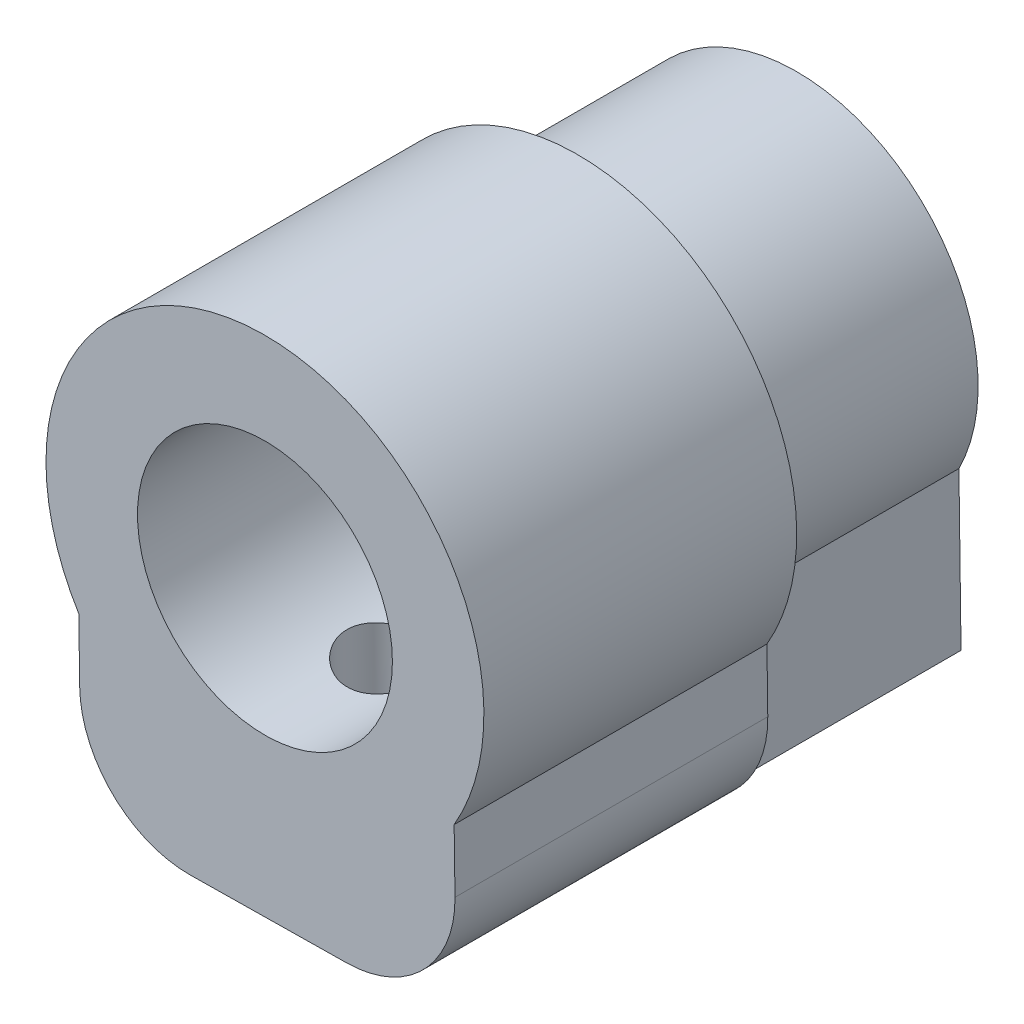
from build123d import *

# Parameters (mm, degrees)
BOSS_EXTRUDE1_DEPTH = 7
BOSS_EXTRUDE3_DEPTH = 10
SKETCH6_R           = 1.35
CUT_EXTRUDE3_DEPTH  = 12
FILLET1_R           = 3.5
FILLET2_R           = 3.5


with BuildPart() as part:
    # Sketch1 → Boss-Extrude1 (new body)
    with BuildSketch(Plane.XY):
        with BuildLine():
            ThreePointArc((5.050452833, -4.633288902), (-0.057176836, -7.835700867), (-5.249547167, -4.77259565))
            Line((-5.249547167, -4.77259565), (-5.181922533, -9.77259565))
            Line((-5.181922533, -9.77259565), (5.118077467, -9.633288902))
            Line((5.118077467, -9.633288902), (5.050452833, -4.633288902))
        make_face()
        with BuildLine():
            ThreePointArc((5.664385761, -2.036231273), (-1.546144107, 3.589638037), (-5.249547167, -4.77259565))
            Line((-5.249547167, -4.77259565), (5.050452833, -4.633288902))
            ThreePointArc((5.050452833, -4.633288902), (5.508816158, -3.370549635), (5.664385761, -2.036231273))
        make_face()
        with BuildLine():
            Line((5.050452833, -4.633288902), (-5.249547167, -4.77259565))
            ThreePointArc((-5.249547167, -4.77259565), (-0.057176836, -7.835700867), (5.050452833, -4.633288902))
        make_face()
    extrude(amount=BOSS_EXTRUDE1_DEPTH)

    # Sketch2 → Boss-Extrude3 (add)
    with BuildSketch(Plane.XY.offset(7)):
        with BuildLine():
            Line((5.063146119, -5.571799449), (5.912597424, -5.560310683))
            ThreePointArc((5.912597424, -5.560310683), (6.622250869, -3.861405013), (6.864385761, -2.036231273))
            ThreePointArc((6.864385761, -2.036231273), (-2.052012342, 4.696332749), (-6.086305185, -5.722594964))
            Line((-6.086305185, -5.722594964), (-5.236853881, -5.711106197))
            Line((-5.236853881, -5.711106197), (-5.249547167, -4.77259565))
            ThreePointArc((-5.249547167, -4.77259565), (-0.214051642, 3.763238321), (5.050452833, -4.633288902))
            Line((5.050452833, -4.633288902), (5.063146119, -5.571799449))
        make_face()
        with BuildLine():
            Line((1.811820806, -5.615773387), (5.063146119, -5.571799449))
            Line((5.063146119, -5.571799449), (5.050452833, -4.633288902))
            ThreePointArc((5.050452833, -4.633288902), (-0.214051642, 3.763238321), (-5.249547167, -4.77259565))
            Line((-5.249547167, -4.77259565), (-5.236853881, -5.711106197))
            Line((-5.236853881, -5.711106197), (-1.985528568, -5.66713226))
            ThreePointArc((-1.985528568, -5.66713226), (-2.264842281, 1.438248968), (3.939385761, -2.036231273))
            ThreePointArc((3.939385761, -2.036231273), (3.367343284, -4.118276805), (1.811820806, -5.615773387))
        make_face()
        with BuildLine():
            Line((5.078495254, -6.706676883), (5.063146119, -5.571799449))
            Line((5.063146119, -5.571799449), (1.811820806, -5.615773387))
            ThreePointArc((1.811820806, -5.615773387), (-0.080505202, -6.110858617), (-1.985528568, -5.66713226))
            Line((-1.985528568, -5.66713226), (-5.236853881, -5.711106197))
            Line((-5.236853881, -5.711106197), (-5.221504746, -6.845983631))
            ThreePointArc((-5.221504746, -6.845983631), (-0.040948408, -9.035591128), (5.078495254, -6.706676883))
        make_face()
        with BuildLine():
            Line((5.118077467, -9.633288902), (5.078495254, -6.706676883))
            ThreePointArc((5.078495254, -6.706676883), (-0.040948408, -9.035591128), (-5.221504746, -6.845983631))
            Line((-5.221504746, -6.845983631), (-5.181922533, -9.77259565))
            Line((-5.181922533, -9.77259565), (5.118077467, -9.633288902))
        make_face()
        with BuildLine():
            Line((5.986984522, -11.060310683), (5.912597424, -5.560310683))
            ThreePointArc((5.912597424, -5.560310683), (5.524642674, -6.154664432), (5.078495254, -6.706676883))
            Line((5.078495254, -6.706676883), (5.118077467, -9.633288902))
            Line((5.118077467, -9.633288902), (-5.181922533, -9.77259565))
            Line((-5.181922533, -9.77259565), (-5.221504746, -6.845983631))
            ThreePointArc((-5.221504746, -6.845983631), (-5.6824181, -6.30623911), (-6.086305185, -5.722594964))
            Line((-6.086305185, -5.722594964), (-6.011918087, -11.222594964))
            Line((-6.011918087, -11.222594964), (5.986984522, -11.060310683))
        make_face()
        with BuildLine():
            ThreePointArc((5.078495254, -6.706676883), (5.524642674, -6.154664432), (5.912597424, -5.560310683))
            Line((5.912597424, -5.560310683), (5.063146119, -5.571799449))
            Line((5.063146119, -5.571799449), (5.078495254, -6.706676883))
        make_face()
        with BuildLine():
            Line((-5.236853881, -5.711106197), (-6.086305185, -5.722594964))
            ThreePointArc((-6.086305185, -5.722594964), (-5.6824181, -6.30623911), (-5.221504746, -6.845983631))
            Line((-5.221504746, -6.845983631), (-5.236853881, -5.711106197))
        make_face()
    extrude(amount=BOSS_EXTRUDE3_DEPTH)

    # Sketch6 → Cut-Extrude3 (cut)
    with BuildSketch(Plane(origin=(0.150657496, -11.139246579, 0), x_dir=(-0.999908551, -0.01352369, 0), z_dir=(0.01352369, -0.999908551, 0))):
        with Locations((0.241163233, -13)):
            Circle(SKETCH6_R)
    extrude(amount=-CUT_EXTRUDE3_DEPTH, mode=Mode.SUBTRACT)

    # Fillet1
    fillet1_edges = [part.edges().sort_by_distance(p)[0] for p in [
        (5.986984522, -11.060310683, 12),
    ]]
    fillet(fillet1_edges, radius=FILLET1_R)

    # Fillet2
    fillet2_edges = [part.edges().sort_by_distance(p)[0] for p in [
        (-6.011918087, -11.222594964, 12),
    ]]
    fillet(fillet2_edges, radius=FILLET2_R)


solid = part.part
